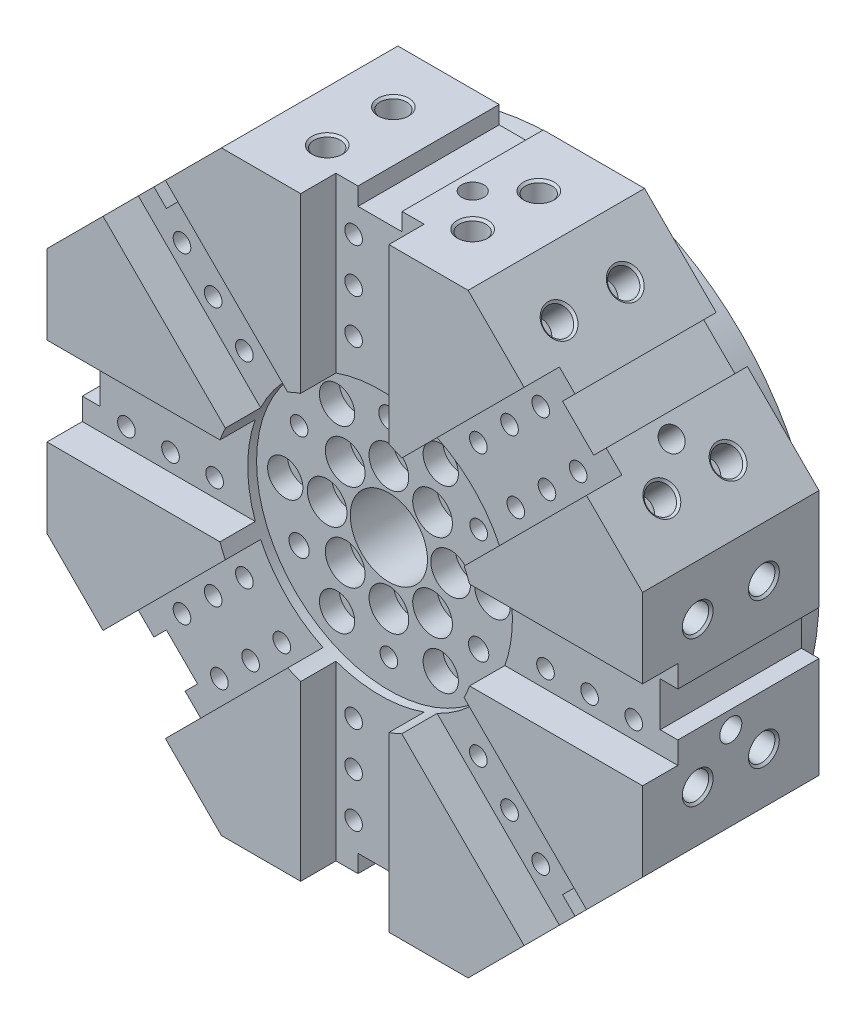
from build123d import *

# Parameters (mm, degrees)
EXTRUDE_3_DEPTH                    = 80
SKETCH_8_R                         = 60
CUT_EXTRUDE_3_DEPTH                = 20
CUT_EXTRUDE_4_DEPTH                = 16
SKETCH_10_W                        = 8
SKETCH_10_H                        = 20
CUT_EXTRUDE_5_DEPTH                = 146
PATTERN_CIRCULAR_2_COUNT           = 8
SKETCH_11_R                        = 4
CUT_EXTRUDE_6_DEPTH                = 15
PATTERN_CIRCULAR_3_COUNT           = 8
SKETCH_12_R                        = 6
CUT_EXTRUDE_7_DEPTH                = 15
CHAMFER_1_SIZE                     = 1
CHAMFER_2_SIZE                     = 1
PATTERN_CIRCULAR_6_COUNT           = 8
PATTERN_CIRCULAR_6_COPY_1_SKETCH_R = 6
PATTERN_CIRCULAR_6_COPY_1_DEPTH    = 15
PATTERN_CIRCULAR_6_COPY_2_SKETCH_R = 6
PATTERN_CIRCULAR_6_COPY_2_DEPTH    = 15
PATTERN_CIRCULAR_6_COPY_3_SKETCH_R = 6
PATTERN_CIRCULAR_6_COPY_3_DEPTH    = 15
PATTERN_CIRCULAR_6_COPY_4_SKETCH_R = 6
PATTERN_CIRCULAR_6_COPY_4_DEPTH    = 15
PATTERN_CIRCULAR_6_COPY_5_SKETCH_R = 6
PATTERN_CIRCULAR_6_COPY_5_DEPTH    = 15
PATTERN_CIRCULAR_6_COPY_6_SKETCH_R = 6
PATTERN_CIRCULAR_6_COPY_6_DEPTH    = 15
PATTERN_CIRCULAR_6_COPY_7_SKETCH_R = 6
PATTERN_CIRCULAR_6_COPY_7_DEPTH    = 15
CHAMFER_3_SIZE                     = 1
SKETCH_13_R                        = 120
EXTRUDE_4_DEPTH                    = 15
SKETCH_14_R                        = 5
SKETCH_14_R_2                      = 4
CUT_EXTRUDE_8_DEPTH                = 35
SKETCH_15_R                        = 17.5
CUT_EXTRUDE_9_DEPTH                = 85
SKETCH_16_R                        = 8
CUT_EXTRUDE_10_DEPTH               = 9
SKETCH_17_R                        = 9
CUT_EXTRUDE_11_DEPTH               = 11
SKETCH_18_R                        = 4
CUT_EXTRUDE_12_DEPTH               = 8
PATTERN_CIRCULAR_7_COUNT           = 3
SKETCH_19_R                        = 85
CUT_EXTRUDE_13_DEPTH               = 40
SKETCH_20_R                        = 4.6
CUT_EXTRUDE_14_DEPTH               = 143
SKETCH_21_R                        = 5
CUT_EXTRUDE_15_DEPTH               = 50
PATTERN_CIRCULAR_8_COUNT           = 8
SKETCH_22_R                        = 5
CUT_EXTRUDE_16_DEPTH               = 65
PATTERN_CIRCULAR_9_COUNT           = 8


with BuildPart() as part:
    # 草图7 → 凸台-拉伸3 (new body)
    with BuildSketch(Plane.XY):
        Polygon((55.91883092, 135), (-55.91883092, 135), (-135, 55.91883092), (-135, -55.91883092), (-55.91883092, -135), (55.91883092, -135), (135, -55.91883092), (135, 55.91883092), align=None)
    extrude(amount=EXTRUDE_3_DEPTH)

    # 草图8 → 切除-拉伸3 (cut)
    with BuildSketch(Plane.XY.offset(80)):
        Circle(SKETCH_8_R)
    extrude(amount=-CUT_EXTRUDE_3_DEPTH, mode=Mode.SUBTRACT)

    # 草图9 → 切除-拉伸4 (cut)
    with BuildSketch(Plane.XY.offset(80)):
        with BuildLine():
            Line((135, -20), (135, 20))
            Line((135, 20), (56.568542495, 20))
            ThreePointArc((56.568542495, 20), (60, 0), (56.568542495, -20))
            Line((56.568542495, -20), (135, -20))
        make_face()
        with BuildLine():
            Line((81.317279836, -109.601551084), (109.601551084, -81.317279836))
            Line((109.601551084, -81.317279836), (54.142135624, -25.857864376))
            ThreePointArc((54.142135624, -25.857864376), (42.426406871, -42.426406871), (25.857864376, -54.142135624))
            Line((25.857864376, -54.142135624), (81.317279836, -109.601551084))
        make_face()
        with BuildLine():
            Line((-20, -135), (20, -135))
            Line((20, -135), (20, -56.568542495))
            ThreePointArc((20, -56.568542495), (0, -60), (-20, -56.568542495))
            Line((-20, -56.568542495), (-20, -135))
        make_face()
        with BuildLine():
            Line((-109.601551084, -81.317279836), (-81.317279836, -109.601551084))
            Line((-81.317279836, -109.601551084), (-25.857864376, -54.142135624))
            ThreePointArc((-25.857864376, -54.142135624), (-42.426406871, -42.426406871), (-54.142135624, -25.857864376))
            Line((-54.142135624, -25.857864376), (-109.601551084, -81.317279836))
        make_face()
        with BuildLine():
            Line((-135, 20), (-135, -20))
            Line((-135, -20), (-56.568542495, -20))
            ThreePointArc((-56.568542495, -20), (-60, 0), (-56.568542495, 20))
            Line((-56.568542495, 20), (-135, 20))
        make_face()
        with BuildLine():
            Line((-81.317279836, 109.601551084), (-109.601551084, 81.317279836))
            Line((-109.601551084, 81.317279836), (-54.142135624, 25.857864376))
            ThreePointArc((-54.142135624, 25.857864376), (-42.426406871, 42.426406871), (-25.857864376, 54.142135624))
            Line((-25.857864376, 54.142135624), (-81.317279836, 109.601551084))
        make_face()
        with BuildLine():
            Line((20, 135), (-20, 135))
            Line((-20, 135), (-20, 56.568542495))
            ThreePointArc((-20, 56.568542495), (0, 60), (20, 56.568542495))
            Line((20, 56.568542495), (20, 135))
        make_face()
        with BuildLine():
            Line((109.601551084, 81.317279836), (81.317279836, 109.601551084))
            Line((81.317279836, 109.601551084), (25.857864376, 54.142135624))
            ThreePointArc((25.857864376, 54.142135624), (42.426406871, 42.426406871), (54.142135624, 25.857864376))
            Line((54.142135624, 25.857864376), (109.601551084, 81.317279836))
        make_face()
    extrude(amount=-CUT_EXTRUDE_4_DEPTH, mode=Mode.SUBTRACT)

    # 草图10 → 切除-拉伸5 (cut)
    with BuildSketch(Plane.XY.offset(64)):
        with Locations((131, 0)):
            Rectangle(SKETCH_10_W, SKETCH_10_H)
    cut_extrude_5 = extrude(amount=-CUT_EXTRUDE_5_DEPTH, mode=Mode.SUBTRACT)

    # 阵列(圆周)2: 切除-拉伸5 ×8 about axis
    pattern_circular_2_axis = Axis((0, 0, 0), (0, 0, 1))
    for i in range(1, PATTERN_CIRCULAR_2_COUNT):
        add(cut_extrude_5.rotate(pattern_circular_2_axis, i * 360 / PATTERN_CIRCULAR_2_COUNT), mode=Mode.SUBTRACT)

    # 草图11 → 切除-拉伸6 (cut)
    with BuildSketch(Plane.XY.offset(64)):
        with Locations((115, 12)):
            Circle(SKETCH_11_R)
        with Locations((95, 12)):
            Circle(SKETCH_11_R)
        with Locations((75, 12)):
            Circle(SKETCH_11_R)
        with Locations((75, -12)):
            Circle(SKETCH_11_R)
        with Locations((95, -12)):
            Circle(SKETCH_11_R)
        with Locations((115, -12)):
            Circle(SKETCH_11_R)
    cut_extrude_6 = extrude(amount=-CUT_EXTRUDE_6_DEPTH, mode=Mode.SUBTRACT)

    # 阵列(圆周)3: 切除-拉伸6 ×8 about axis
    pattern_circular_3_axis = Axis((0, 0, 0), (0, 0, 1))
    for i in range(1, PATTERN_CIRCULAR_3_COUNT):
        add(cut_extrude_6.rotate(pattern_circular_3_axis, i * 360 / PATTERN_CIRCULAR_3_COUNT), mode=Mode.SUBTRACT)

    # 草图12 → 切除-拉伸7 (cut)
    with BuildSketch(Plane(origin=(135, 0, 0), x_dir=(0, 0, -1), z_dir=(1, 0, 0))):
        with Locations((-25, 32.95941546)):
            Circle(SKETCH_12_R)
        with Locations((-55, 32.95941546)):
            Circle(SKETCH_12_R)
    cut_extrude_7 = extrude(amount=-CUT_EXTRUDE_7_DEPTH, mode=Mode.SUBTRACT)

    # 倒角1
    chamfer_1_edges = [part.edges().sort_by_distance(p)[0] for p in [
        (135, 32.95941546, 31),
        (135, 32.95941546, 61),
    ]]
    chamfer(chamfer_1_edges, length=CHAMFER_1_SIZE)

    # 镜向1: 切除-拉伸7 across plane
    add(cut_extrude_7.mirror(Plane.ZX), mode=Mode.SUBTRACT)

    # 倒角2
    chamfer_2_edges = [part.edges().sort_by_distance(p)[0] for p in [
        (135, -32.95941546, 31),
        (135, -32.95941546, 61),
        (120, -32.95941546, 61),
    ]]
    chamfer(chamfer_2_edges, length=CHAMFER_2_SIZE)

    # 阵列(圆周)6: 切除-拉伸7 ×8 about axis
    pattern_circular_6_axis = Axis((0, 0, 0), (0, 0, 1))
    for i in range(1, PATTERN_CIRCULAR_6_COUNT):
        add(cut_extrude_7.rotate(pattern_circular_6_axis, i * 360 / PATTERN_CIRCULAR_6_COUNT), mode=Mode.SUBTRACT)

    # 阵列(圆周)6 copy 1 sketch → 阵列(圆周)6 copy 1 (cut)
    with BuildSketch(Plane(origin=(95.45941546, 95.45941546, 0), x_dir=(0, 0, -1), z_dir=(0.707106781, 0.707106781, 0))):
        with Locations((-25, -32.95941546)):
            Circle(PATTERN_CIRCULAR_6_COPY_1_SKETCH_R)
        with Locations((-55, -32.95941546)):
            Circle(PATTERN_CIRCULAR_6_COPY_1_SKETCH_R)
    extrude(amount=-PATTERN_CIRCULAR_6_COPY_1_DEPTH, mode=Mode.SUBTRACT)

    # 阵列(圆周)6 copy 2 sketch → 阵列(圆周)6 copy 2 (cut)
    with BuildSketch(Plane(origin=(0, 135, 0), x_dir=(0, 0, -1), z_dir=(0, 1, 0))):
        with Locations((-25, -32.95941546)):
            Circle(PATTERN_CIRCULAR_6_COPY_2_SKETCH_R)
        with Locations((-55, -32.95941546)):
            Circle(PATTERN_CIRCULAR_6_COPY_2_SKETCH_R)
    extrude(amount=-PATTERN_CIRCULAR_6_COPY_2_DEPTH, mode=Mode.SUBTRACT)

    # 阵列(圆周)6 copy 3 sketch → 阵列(圆周)6 copy 3 (cut)
    with BuildSketch(Plane(origin=(-95.45941546, 95.45941546, 0), x_dir=(0, 0, -1), z_dir=(-0.707106781, 0.707106781, 0))):
        with Locations((-25, -32.95941546)):
            Circle(PATTERN_CIRCULAR_6_COPY_3_SKETCH_R)
        with Locations((-55, -32.95941546)):
            Circle(PATTERN_CIRCULAR_6_COPY_3_SKETCH_R)
    extrude(amount=-PATTERN_CIRCULAR_6_COPY_3_DEPTH, mode=Mode.SUBTRACT)

    # 阵列(圆周)6 copy 4 sketch → 阵列(圆周)6 copy 4 (cut)
    with BuildSketch(Plane(origin=(-135, 0, 0), x_dir=(0, 0, -1), z_dir=(-1, 0, 0))):
        with Locations((-25, -32.95941546)):
            Circle(PATTERN_CIRCULAR_6_COPY_4_SKETCH_R)
        with Locations((-55, -32.95941546)):
            Circle(PATTERN_CIRCULAR_6_COPY_4_SKETCH_R)
    extrude(amount=-PATTERN_CIRCULAR_6_COPY_4_DEPTH, mode=Mode.SUBTRACT)

    # 阵列(圆周)6 copy 5 sketch → 阵列(圆周)6 copy 5 (cut)
    with BuildSketch(Plane(origin=(-95.45941546, -95.45941546, 0), x_dir=(0, 0, -1), z_dir=(-0.707106781, -0.707106781, 0))):
        with Locations((-25, -32.95941546)):
            Circle(PATTERN_CIRCULAR_6_COPY_5_SKETCH_R)
        with Locations((-55, -32.95941546)):
            Circle(PATTERN_CIRCULAR_6_COPY_5_SKETCH_R)
    extrude(amount=-PATTERN_CIRCULAR_6_COPY_5_DEPTH, mode=Mode.SUBTRACT)

    # 阵列(圆周)6 copy 6 sketch → 阵列(圆周)6 copy 6 (cut)
    with BuildSketch(Plane(origin=(0, -135, 0), x_dir=(0, 0, -1), z_dir=(0, -1, 0))):
        with Locations((-25, -32.95941546)):
            Circle(PATTERN_CIRCULAR_6_COPY_6_SKETCH_R)
        with Locations((-55, -32.95941546)):
            Circle(PATTERN_CIRCULAR_6_COPY_6_SKETCH_R)
    extrude(amount=-PATTERN_CIRCULAR_6_COPY_6_DEPTH, mode=Mode.SUBTRACT)

    # 阵列(圆周)6 copy 7 sketch → 阵列(圆周)6 copy 7 (cut)
    with BuildSketch(Plane(origin=(95.45941546, -95.45941546, 0), x_dir=(0, 0, -1), z_dir=(0.707106781, -0.707106781, 0))):
        with Locations((-25, -32.95941546)):
            Circle(PATTERN_CIRCULAR_6_COPY_7_SKETCH_R)
        with Locations((-55, -32.95941546)):
            Circle(PATTERN_CIRCULAR_6_COPY_7_SKETCH_R)
    extrude(amount=-PATTERN_CIRCULAR_6_COPY_7_DEPTH, mode=Mode.SUBTRACT)

    # 倒角3
    chamfer_3_edges = [part.edges().sort_by_distance(p)[0] for p in [
        (72.153589284, 118.765241636, 31),
        (72.153589284, 118.765241636, 61),
        (-32.95941546, 135, 31),
        (-32.95941546, 135, 61),
        (-118.765241636, 72.153589284, 31),
        (-118.765241636, 72.153589284, 61),
        (-135, -32.95941546, 31),
        (-135, -32.95941546, 61),
        (-72.153589284, -118.765241636, 31),
        (-72.153589284, -118.765241636, 61),
        (32.95941546, -135, 31),
        (32.95941546, -135, 61),
        (118.765241636, -72.153589284, 31),
        (118.765241636, -72.153589284, 61),
        (118.765241636, 72.153589284, 31),
        (118.765241636, 72.153589284, 61),
        (32.95941546, 135, 31),
        (32.95941546, 135, 61),
        (-72.153589284, 118.765241636, 31),
        (-72.153589284, 118.765241636, 61),
        (-135, 32.95941546, 31),
        (-135, 32.95941546, 61),
        (-118.765241636, -72.153589284, 31),
        (-118.765241636, -72.153589284, 61),
        (-32.95941546, -135, 31),
        (-32.95941546, -135, 61),
        (72.153589284, -118.765241636, 31),
        (72.153589284, -118.765241636, 61),
    ]]
    chamfer(chamfer_3_edges, length=CHAMFER_3_SIZE)

    # 草图13 → 凸台-拉伸4 (add)
    with BuildSketch(Plane(origin=(0, 0, 0), x_dir=(-1, 0, 0), z_dir=(0, 0, -1))):
        Circle(SKETCH_13_R)
    extrude(amount=EXTRUDE_4_DEPTH)

    # 草图14 → 切除-拉伸8 (cut)
    with BuildSketch(Plane.XY.offset(60)):
        with Locations((28, 0)):
            Circle(SKETCH_14_R)
        with Locations((47, 0)):
            Circle(SKETCH_14_R_2)
        with Locations((19.798989873, -19.798989873)):
            Circle(SKETCH_14_R)
        with Locations((0, -28)):
            Circle(SKETCH_14_R)
        with Locations((-19.798989873, -19.798989873)):
            Circle(SKETCH_14_R)
        with Locations((-28, 0)):
            Circle(SKETCH_14_R)
        with Locations((-19.798989873, 19.798989873)):
            Circle(SKETCH_14_R)
        with Locations((0, 28)):
            Circle(SKETCH_14_R)
        with Locations((19.798989873, 19.798989873)):
            Circle(SKETCH_14_R)
        with Locations((23.5, -40.703193978)):
            Circle(SKETCH_14_R_2)
        with Locations((-23.5, -40.703193978)):
            Circle(SKETCH_14_R_2)
        with Locations((-47, 0)):
            Circle(SKETCH_14_R_2)
        with Locations((-23.5, 40.703193978)):
            Circle(SKETCH_14_R_2)
        with Locations((23.5, 40.703193978)):
            Circle(SKETCH_14_R_2)
    extrude(amount=-CUT_EXTRUDE_8_DEPTH, mode=Mode.SUBTRACT)

    # 草图15 → 切除-拉伸9 (cut)
    with BuildSketch(Plane.XY.offset(60)):
        Circle(SKETCH_15_R)
    extrude(amount=-CUT_EXTRUDE_9_DEPTH, mode=Mode.SUBTRACT)

    # 草图16 → 切除-拉伸10 (cut)
    with BuildSketch(Plane.XY.offset(60)):
        with Locations((47, 0)):
            Circle(SKETCH_16_R)
        with Locations((23.5, -40.703193978)):
            Circle(SKETCH_16_R)
        with Locations((-23.5, -40.703193978)):
            Circle(SKETCH_16_R)
        with Locations((-47, 0)):
            Circle(SKETCH_16_R)
        with Locations((-23.5, 40.703193978)):
            Circle(SKETCH_16_R)
        with Locations((23.5, 40.703193978)):
            Circle(SKETCH_16_R)
    extrude(amount=-CUT_EXTRUDE_10_DEPTH, mode=Mode.SUBTRACT)

    # 草图17 → 切除-拉伸11 (cut)
    with BuildSketch(Plane.XY.offset(60)):
        with Locations((28, 0)):
            Circle(SKETCH_17_R)
        with Locations((19.798989873, 19.798989873)):
            Circle(SKETCH_17_R)
        with Locations((19.798989873, -19.798989873)):
            Circle(SKETCH_17_R)
        with Locations((0, -28)):
            Circle(SKETCH_17_R)
        with Locations((-19.798989873, -19.798989873)):
            Circle(SKETCH_17_R)
        with Locations((-28, 0)):
            Circle(SKETCH_17_R)
        with Locations((-19.798989873, 19.798989873)):
            Circle(SKETCH_17_R)
        with Locations((0, 28)):
            Circle(SKETCH_17_R)
    extrude(amount=-CUT_EXTRUDE_11_DEPTH, mode=Mode.SUBTRACT)

    # 草图18 → 切除-拉伸12 (cut)
    with BuildSketch(Plane.XY.offset(60)):
        with Locations((0, -47)):
            Circle(SKETCH_18_R)
    cut_extrude_12 = extrude(amount=-CUT_EXTRUDE_12_DEPTH, mode=Mode.SUBTRACT)

    # 阵列(圆周)7: 切除-拉伸12 ×3 about axis
    pattern_circular_7_axis = Axis((0, 0, 0), (0, 0, 1))
    for i in range(1, PATTERN_CIRCULAR_7_COUNT):
        add(cut_extrude_12.rotate(pattern_circular_7_axis, i * 360 / PATTERN_CIRCULAR_7_COUNT), mode=Mode.SUBTRACT)

    # 草图19 → 切除-拉伸13 (cut)
    with BuildSketch(Plane(origin=(0, 0, -15), x_dir=(-1, 0, 0), z_dir=(0, 0, -1))):
        Circle(SKETCH_19_R)
    extrude(amount=-CUT_EXTRUDE_13_DEPTH, mode=Mode.SUBTRACT)

    # 草图20 → 切除-拉伸14 (cut)
    with BuildSketch(Plane.XY.offset(60)):
        with Locations((40.703193978, -23.5)):
            Circle(SKETCH_20_R)
        with Locations((-40.703193978, -23.5)):
            Circle(SKETCH_20_R)
        with Locations((0, 47)):
            Circle(SKETCH_20_R)
    extrude(amount=-CUT_EXTRUDE_14_DEPTH, mode=Mode.SUBTRACT)

    # 草图21 → 切除-拉伸15 (cut)
    with BuildSketch(Plane(origin=(95.45941546, 95.45941546, 0), x_dir=(0, 0, -1), z_dir=(0.707106781, 0.707106781, 0))):
        with Locations((-40, -18)):
            Circle(SKETCH_21_R)
    cut_extrude_15 = extrude(amount=-CUT_EXTRUDE_15_DEPTH, mode=Mode.SUBTRACT)

    # 阵列(圆周)8: 切除-拉伸15 ×8 about axis
    pattern_circular_8_axis = Axis((0, 0, 0), (0, 0, 1))
    for i in range(1, PATTERN_CIRCULAR_8_COUNT):
        add(cut_extrude_15.rotate(pattern_circular_8_axis, i * 360 / PATTERN_CIRCULAR_8_COUNT), mode=Mode.SUBTRACT)

    # 草图22 → 切除-拉伸16 (cut)
    with BuildSketch(Plane(origin=(0, 0, -15), x_dir=(-1, 0, 0), z_dir=(0, 0, -1))):
        with Locations((-98.259553459, -18.004661371)):
            Circle(SKETCH_22_R)
    cut_extrude_16 = extrude(amount=-CUT_EXTRUDE_16_DEPTH, mode=Mode.SUBTRACT)

    # 阵列(圆周)9: 切除-拉伸16 ×8 about axis
    pattern_circular_9_axis = Axis((0, 0, 0), (0, 0, 1))
    for i in range(1, PATTERN_CIRCULAR_9_COUNT):
        add(cut_extrude_16.rotate(pattern_circular_9_axis, i * 360 / PATTERN_CIRCULAR_9_COUNT), mode=Mode.SUBTRACT)


solid = part.part
